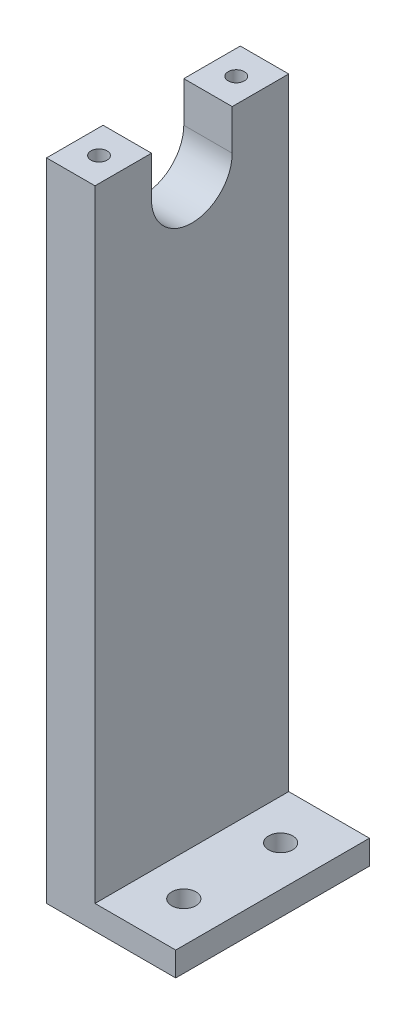
from build123d import *

# Parameters (mm, degrees)
SKETCH1_W           = 3
SKETCH1_H           = 12
BOSS_EXTRUDE1_DEPTH = 40
CUT_EXTRUDE1_DEPTH  = 3
SKETCH3_R           = 0.5
CUT_EXTRUDE2_DEPTH  = 5
SKETCH4_W           = 12
SKETCH4_H           = 1.5
BOSS_EXTRUDE2_DEPTH = 5
SKETCH5_R           = 0.75
CUT_EXTRUDE3_DEPTH  = 5


with BuildPart() as part:
    # Sketch1 → Boss-Extrude1 (new body)
    with BuildSketch(Plane(origin=(0, 0, 0), x_dir=(1, 0, 0), z_dir=(0, 1, 0))):
        Rectangle(SKETCH1_W, SKETCH1_H)
    extrude(amount=BOSS_EXTRUDE1_DEPTH)

    # Sketch2 → Cut-Extrude1 (cut)
    with BuildSketch(Plane(origin=(1.5, 0, 0), x_dir=(0, 0, -1), z_dir=(1, 0, 0))):
        with BuildLine():
            Line((-2.5, 40), (-2.5, 37.5))
            ThreePointArc((-2.5, 37.5), (0, 35), (2.5, 37.5))
            Line((2.5, 37.5), (2.5, 40))
            Line((2.5, 40), (-2.5, 40))
        make_face()
    extrude(amount=-CUT_EXTRUDE1_DEPTH, mode=Mode.SUBTRACT)

    # Sketch3 → Cut-Extrude2 (cut)
    with BuildSketch(Plane(origin=(0, 40, 0), x_dir=(1, 0, 0), z_dir=(0, 1, 0))):
        with Locations((0, -4.25)):
            Circle(SKETCH3_R)
        with Locations((0, 4.25)):
            Circle(SKETCH3_R)
    extrude(amount=-CUT_EXTRUDE2_DEPTH, mode=Mode.SUBTRACT)

    # Sketch4 → Boss-Extrude2 (add)
    with BuildSketch(Plane(origin=(1.5, 0, 0), x_dir=(0, 0, -1), z_dir=(1, 0, 0))):
        with Locations((0, 0.75)):
            Rectangle(SKETCH4_W, SKETCH4_H)
    extrude(amount=BOSS_EXTRUDE2_DEPTH)

    # Sketch5 → Cut-Extrude3 (cut)
    with BuildSketch(Plane(origin=(0, 1.5, 0), x_dir=(1, 0, 0), z_dir=(0, 1, 0))):
        with Locations((4, 3)):
            Circle(SKETCH5_R)
        with Locations((4, -3)):
            Circle(SKETCH5_R)
    extrude(amount=-CUT_EXTRUDE3_DEPTH, mode=Mode.SUBTRACT)


solid = part.part
